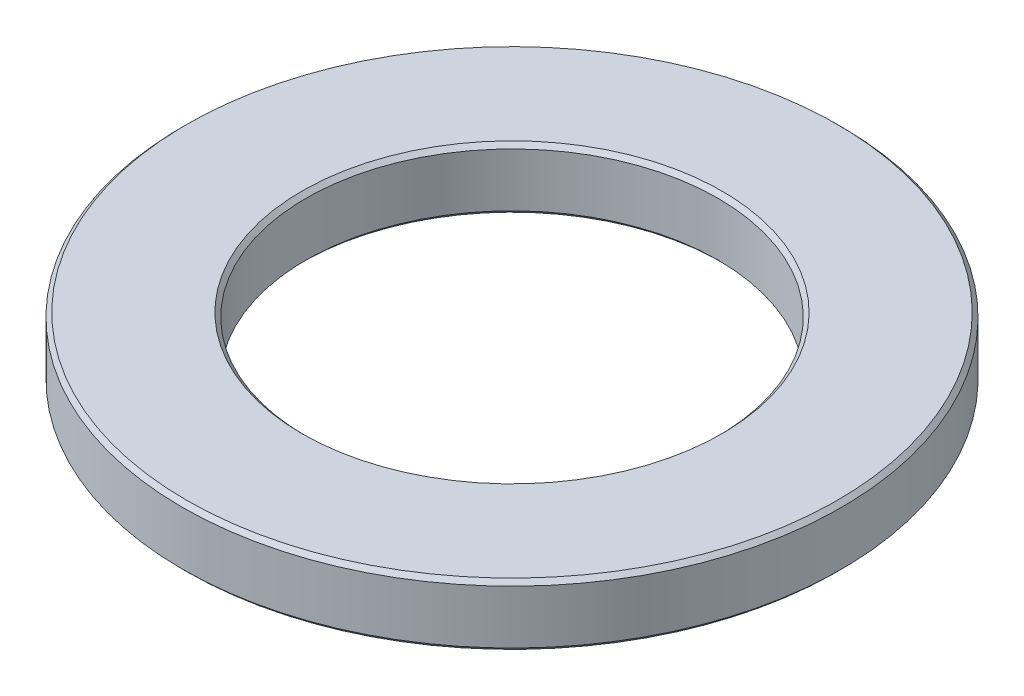
from build123d import *

# Parameters (mm, degrees)
PROFILES_R    = 8
PROFILES_R_2  = 5
PROFILE_DEPTH = 1.5
OUTERC_SIZE   = 0.1
INNERC_SIZE   = 0.1


with BuildPart() as part:
    # ProfileS → Profile (new body)
    with BuildSketch(Plane(origin=(0, 0, 0), x_dir=(1, 0, 0), z_dir=(0, 1, 0))):
        Circle(PROFILES_R)
        Circle(PROFILES_R_2, mode=Mode.SUBTRACT)
    extrude(amount=PROFILE_DEPTH)

    # OuterC
    outerc_edges = [part.edges().sort_by_distance(p)[0] for p in [
        (-8, 0, 0),
        (-8, 1.5, 0),
    ]]
    chamfer(outerc_edges, length=OUTERC_SIZE)

    # InnerC
    innerc_edges = [part.edges().sort_by_distance(p)[0] for p in [
        (-5, 0, 0),
        (-5, 1.5, 0),
    ]]
    chamfer(innerc_edges, length=INNERC_SIZE)


solid = part.part
